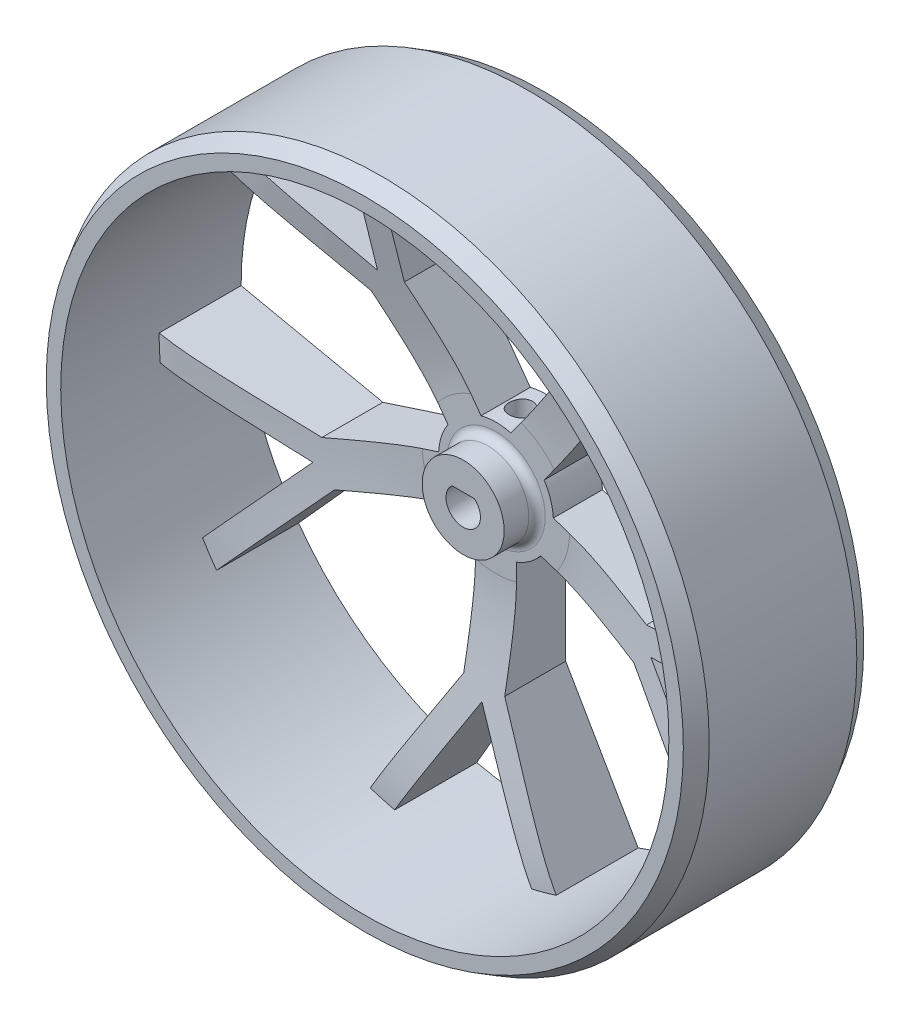
from build123d import *

# Parameters (mm, degrees)
BOSS_EXTRUDE1_DEPTH   = 10
BOSS_EXTRUDE1_2_DEPTH = 10
BOSS_EXTRUDE1_3_DEPTH = 10
BOSS_EXTRUDE1_4_DEPTH = 10
BOSS_EXTRUDE1_5_DEPTH = 10
SKETCH1_6_R           = 40
SKETCH1_6_R_2         = 37.081028238
BOSS_EXTRUDE3_DEPTH   = 22
SKETCH1_7_R           = 7
BOSS_EXTRUDE4_DEPTH   = 10
CHAMFER1_SIZE         = 2
CHAMFER1_SIZE2        = 1.154700538
CHAMFER2_SIZE         = 2
CHAMFER2_SIZE2        = 1.154700538
SKETCH4_R             = 1.42
CUT_EXTRUDE1_DEPTH    = 10


with BuildPart() as part:
    # Sketch1 → Boss-Extrude1 (new body)
    with BuildSketch(Plane.XY):
        with BuildLine():
            Line((2.5, -20), (2.5, -6.538348415))
            ThreePointArc((2.5, -6.538348415), (0, -7), (-2.5, -6.538348415))
            Line((-2.5, -6.538348415), (-2.5, -20))
            Line((-2.5, -20), (-11.336669325, -35.30556024))
            ThreePointArc((-11.336669325, -35.30556024), (-9.85096764, -35.748581675), (-8.348045942, -36.129112696))
            Line((-8.348045942, -36.129112696), (0, -21.669872981))
            Line((0, -21.669872981), (8.348045942, -36.129112696))
            ThreePointArc((8.348045942, -36.129112696), (9.85096764, -35.748581675), (11.336669325, -35.30556024))
            Line((11.336669325, -35.30556024), (2.5, -20))
        make_face()
    extrude(amount=BOSS_EXTRUDE1_DEPTH)



with BuildPart() as body_2:
    # Sketch1 → Boss-Extrude1 2 (new body)
    with BuildSketch(Plane.XY):
        with BuildLine():
            ThreePointArc((6.990881352, 0.357180515), (6.657395614, -2.163118961), (5.44579638, -4.398102066))
            Line((5.44579638, -4.398102066), (18.24858784, -8.557981178))
            Line((18.24858784, -8.557981178), (30.074359647, -21.691831344))
            ThreePointArc((30.074359647, -21.691831344), (30.954805139, -20.415746228), (31.781139991, -19.103973306))
            Line((31.781139991, -19.103973306), (20.609273906, -6.696359017))
            Line((20.609273906, -6.696359017), (36.940516123, -3.225046324))
            ThreePointArc((36.940516123, -3.225046324), (37.043037962, -1.678092297), (37.080806608, -0.128204876))
            Line((37.080806608, -0.128204876), (19.793672812, -3.802698597))
            Line((19.793672812, -3.802698597), (6.990881352, 0.357180515))
        make_face()
    extrude(amount=BOSS_EXTRUDE1_2_DEPTH)


with BuildPart() as body_3:
    # Sketch1 → Boss-Extrude1 3 (new body)
    with BuildSketch(Plane.XY):
        with BuildLine():
            Line((-18.24858784, -8.557981178), (-5.44579638, -4.398102066))
            ThreePointArc((-5.44579638, -4.398102066), (-6.657395614, -2.163118961), (-6.990881352, 0.357180515))
            Line((-6.990881352, 0.357180515), (-19.793672812, -3.802698597))
            Line((-19.793672812, -3.802698597), (-37.080806608, -0.128204876))
            ThreePointArc((-37.080806608, -0.128204876), (-37.043037962, -1.678092297), (-36.940516123, -3.225046324))
            Line((-36.940516123, -3.225046324), (-20.609273906, -6.696359017))
            Line((-20.609273906, -6.696359017), (-31.781139991, -19.103973306))
            ThreePointArc((-31.781139991, -19.103973306), (-30.954805139, -20.415746228), (-30.074359647, -21.691831344))
            Line((-30.074359647, -21.691831344), (-18.24858784, -8.557981178))
        make_face()
    extrude(amount=BOSS_EXTRUDE1_3_DEPTH)


with BuildPart() as body_4:
    # Sketch1 → Boss-Extrude1 4 (new body)
    with BuildSketch(Plane.XY):
        with BuildLine():
            Line((-13.778247532, 14.710876757), (-5.865687259, 3.820171852))
            ThreePointArc((-5.865687259, 3.820171852), (-4.114496766, 5.663118961), (-1.820602287, 6.759098114))
            Line((-1.820602287, 6.759098114), (-9.73316256, 17.649803018))
            Line((-9.73316256, 17.649803018), (-11.58052949, 35.226325269))
            ThreePointArc((-11.58052949, 35.226325269), (-13.042888867, 34.711463599), (-14.482448584, 34.135924452))
            Line((-14.482448584, 34.135924452), (-12.737231757, 17.531295508))
            Line((-12.737231757, 17.531295508), (-27.989870657, 24.322207873))
            ThreePointArc((-27.989870657, 24.322207873), (-28.982089331, 23.130956601), (-29.923645776, 21.899271191))
            Line((-29.923645776, 21.899271191), (-13.778247532, 14.710876757))
        make_face()
    extrude(amount=BOSS_EXTRUDE1_4_DEPTH)


with BuildPart() as body_5:
    # Sketch1 → Boss-Extrude1 5 (new body)
    with BuildSketch(Plane.XY):
        with BuildLine():
            ThreePointArc((1.820602287, 6.759098114), (4.114496766, 5.663118961), (5.865687259, 3.820171852))
            Line((5.865687259, 3.820171852), (13.778247532, 14.710876757))
            Line((13.778247532, 14.710876757), (29.923645776, 21.899271191))
            ThreePointArc((29.923645776, 21.899271191), (28.982089331, 23.130956601), (27.989870657, 24.322207873))
            Line((27.989870657, 24.322207873), (12.737231757, 17.531295508))
            Line((12.737231757, 17.531295508), (14.482448584, 34.135924452))
            ThreePointArc((14.482448584, 34.135924452), (13.042888867, 34.711463599), (11.58052949, 35.226325269))
            Line((11.58052949, 35.226325269), (9.73316256, 17.649803018))
            Line((9.73316256, 17.649803018), (1.820602287, 6.759098114))
        make_face()
    extrude(amount=BOSS_EXTRUDE1_5_DEPTH)


with BuildPart() as part_1:
    add(part.part)

    add(body_2.part)  # Boss-Extrude3 merges body 2

    add(body_3.part)  # Boss-Extrude3 merges body 3

    add(body_4.part)  # Boss-Extrude3 merges body 4

    add(body_5.part)  # Boss-Extrude3 merges body 5
    # Sketch1_6 → Boss-Extrude3 (add)
    with BuildSketch(Plane.XY):
        Circle(SKETCH1_6_R)
        Circle(SKETCH1_6_R_2, mode=Mode.SUBTRACT)
    extrude(amount=BOSS_EXTRUDE3_DEPTH)

    # Sketch1_7 → Boss-Extrude4 (add)
    with BuildSketch(Plane.XY):
        Circle(SKETCH1_7_R)
        with BuildLine():
            Line((-1.360147051, 1.6), (1.360147051, 1.6))
            ThreePointArc((1.360147051, 1.6), (0, -2.1), (-1.360147051, 1.6))
        make_face(mode=Mode.SUBTRACT)
    extrude(amount=BOSS_EXTRUDE4_DEPTH)

    # Sketch3 → Cut-Revolve1 (revolve, cut)
    with BuildSketch(Plane(origin=(0, 0, 0), x_dir=(1, 0, 0), z_dir=(0, 1, 0))):
        with BuildLine():
            Line((5, -10), (13, -10))
            Line((13, -10), (37.080806608, -10))
            add(Edge.make_bspline(
                [(9, -6), (15.881037518, -6), (30.46598853, -9.9791202), (37.080806608, -10)],
                knots=[0, 0, 0, 0, 1, 1, 1, 1], degree=3))
            Line((9, -6), (6, -6))
            ThreePointArc((6, -6), (5.292893219, -6.292893219), (5, -7))
            Line((5, -7), (5, -10))
        make_face()
    revolve(axis=Axis((0, 0, 10), (0, 0, -1)), mode=Mode.SUBTRACT)

    # Chamfer1
    chamfer1_edges = [part_1.edges().sort_by_distance(p)[0] for p in [
        (-40, 0, 22),
    ]]
    chamfer1_side = [part_1.faces().sort_by_distance(p)[0] for p in [
        (-40, 0, 11),
    ]]
    chamfer(chamfer1_edges, length=CHAMFER1_SIZE, length2=CHAMFER1_SIZE2, reference=chamfer1_side[0])

    # Chamfer2
    chamfer2_edges = [part_1.edges().sort_by_distance(p)[0] for p in [
        (-40, 0, 0),
    ]]
    chamfer2_side = [part_1.faces().sort_by_distance(p)[0] for p in [
        (-40, 0, 10),
    ]]
    chamfer(chamfer2_edges, length=CHAMFER2_SIZE, length2=CHAMFER2_SIZE2, reference=chamfer2_side[0])

    # Sketch4 → Cut-Extrude1 (cut)
    with BuildSketch(Plane.XZ.offset(-1.6)):
        with Locations((0, 3)):
            Circle(SKETCH4_R)
    extrude(amount=-CUT_EXTRUDE1_DEPTH, mode=Mode.SUBTRACT)


solid = part_1.part
